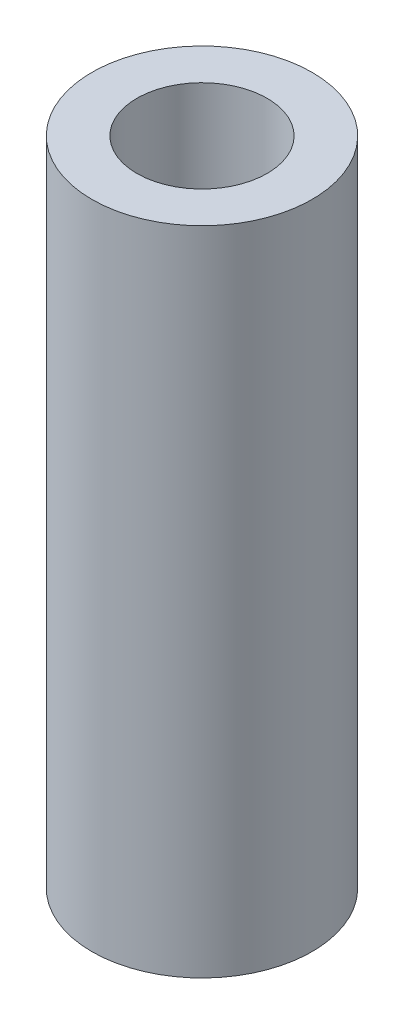
from build123d import *

# Parameters (mm, degrees)
SKETCH1_R           = 10.7315
SKETCH1_R_2         = 6.35
BOSS_EXTRUDE1_DEPTH = 31.75


with BuildPart() as part:
    # Sketch1 → Boss-Extrude1 (new body, symmetric)
    with BuildSketch(Plane(origin=(0, 0, 0), x_dir=(1, 0, 0), z_dir=(0, 1, 0))):
        Circle(SKETCH1_R)
        Circle(SKETCH1_R_2, mode=Mode.SUBTRACT)
    extrude(amount=BOSS_EXTRUDE1_DEPTH, both=True)


solid = part.part
